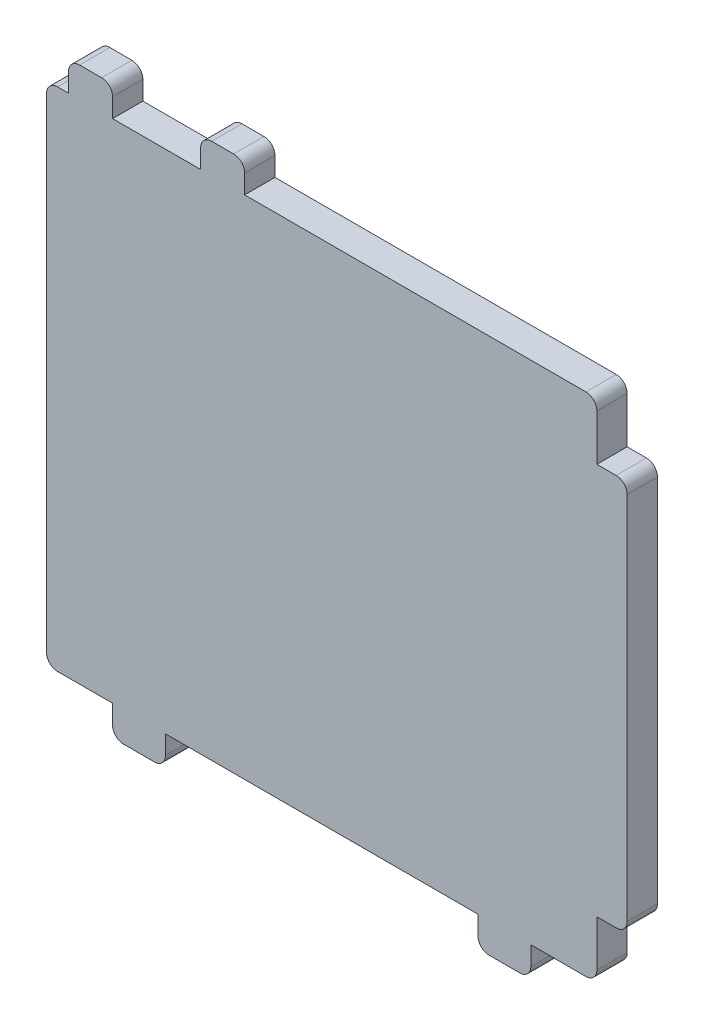
from build123d import *

# Parameters (mm, degrees)
SKETCH1_W           = 125
SKETCH1_H           = 115
BOSS_EXTRUDE1_DEPTH = 6.88
SKETCH2_W           = 10
SKETCH2_H           = 13.6
SKETCH2_W_2         = 12
BOSS_EXTRUDE2_DEPTH = 6.88
SKETCH3_W           = 13.76
SKETCH3_H           = 89
BOSS_EXTRUDE3_DEPTH = 6.88
FILLET1_R           = 2.5


with BuildPart() as part:
    # Sketch1 → Boss-Extrude1 (new body)
    with BuildSketch(Plane.XY):
        Rectangle(SKETCH1_W, SKETCH1_H)
    extrude(amount=BOSS_EXTRUDE1_DEPTH)

    # Sketch2 → Boss-Extrude2 (add)
    with BuildSketch(Plane.XY.offset(6.88)):
        with Locations((-52.5, 57.5)):
            Rectangle(SKETCH2_W, SKETCH2_H)
        with Locations((-22.5, 57.5)):
            Rectangle(SKETCH2_W, SKETCH2_H)
        with Locations((-41.5, -57.5)):
            Rectangle(SKETCH2_W_2, SKETCH2_H)
        with Locations((41.5, -57.5)):
            Rectangle(SKETCH2_W_2, SKETCH2_H)
    extrude(amount=-BOSS_EXTRUDE2_DEPTH)

    # Sketch3 → Boss-Extrude3 (add)
    with BuildSketch(Plane.XY.offset(6.88)):
        with Locations((62.5, 0)):
            Rectangle(SKETCH3_W, SKETCH3_H)
    extrude(amount=-BOSS_EXTRUDE3_DEPTH)

    # Fillet1
    fillet1_edges = [part.edges().sort_by_distance(p)[0] for p in [
        (69.38, -44.5, 3.44),
        (69.38, 44.5, 3.44),
        (-47.5, 64.3, 3.44),
        (-57.5, 64.3, 3.44),
        (-17.5, 64.3, 3.44),
        (-27.5, 64.3, 3.44),
        (-47.5, -64.3, 3.44),
        (-35.5, -64.3, 3.44),
        (-62.5, 57.5, 3.44),
        (62.5, 57.5, 3.44),
        (35.5, -64.3, 3.44),
        (62.5, -57.5, 3.44),
        (-62.5, -57.5, 3.44),
        (47.5, -64.3, 3.44),
    ]]
    fillet(fillet1_edges, radius=FILLET1_R)


solid = part.part
